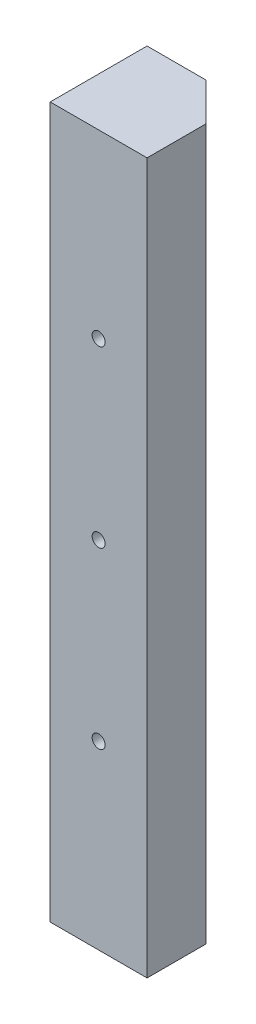
from build123d import *

# Parameters (mm, degrees)
SKETCH1_W                   = 38.1
SKETCH1_H                   = 38.1
BOSS_EXTRUDE1_DEPTH         = 279.4
CHAMFER1_SIZE               = 15
SKETCH15_R                  = 6.35
CUT_EXTRUDE2_DEPTH          = 25
F_1_4_20_TAPPED_HOLE1_D     = 5.1054
F_1_4_20_TAPPED_HOLE1_DEPTH = 20.32
F_1_4_20_TAPPED_HOLE1_TIP   = 1.533816902
F_8_32_TAPPED_HOLE1_REACH   = 285.181
F_8_32_TAPPED_HOLE1_BORE_R  = 1.7272


with BuildPart() as part:
    # Sketch1 → Boss-Extrude1 (new body)
    with BuildSketch(Plane(origin=(0, 0, 0), x_dir=(1, 0, 0), z_dir=(0, 1, 0))):
        with Locations((6.939567467, -5.95)):
            Rectangle(SKETCH1_W, SKETCH1_H)
    extrude(amount=BOSS_EXTRUDE1_DEPTH)

    # Chamfer1
    chamfer1_edges = [part.edges().sort_by_distance(p)[0] for p in [
        (25.989567467, 139.7, -13.1),
    ]]
    chamfer(chamfer1_edges, length=CHAMFER1_SIZE)

    # Sketch15 → Cut-Extrude2 (cut)
    with BuildSketch(Plane(origin=(12.044783734, 0, -12.044783734), x_dir=(-0.7071067811865465, 0, -0.7071067811865487), z_dir=(0.7071067811865487, 0, -0.7071067811865465))):
        with Locations((-9.114300563, 238.76)):
            Circle(SKETCH15_R)
        with Locations((-9.114300563, 177.8)):
            Circle(SKETCH15_R)
        with Locations((-9.114300563, 101.6)):
            Circle(SKETCH15_R)
        with Locations((-9.114300563, 40.64)):
            Circle(SKETCH15_R)
    extrude(amount=-CUT_EXTRUDE2_DEPTH, mode=Mode.SUBTRACT)

    # 1/4-20 Tapped Hole1
    with Locations(Plane.XY.offset(25)):
        with Locations((6.939567467, 208.28), (6.939567467, 139.7), (6.939567467, 71.12)):
            Hole(F_1_4_20_TAPPED_HOLE1_D / 2, depth=F_1_4_20_TAPPED_HOLE1_DEPTH)
            with Locations((0, 0, -(F_1_4_20_TAPPED_HOLE1_DEPTH + F_1_4_20_TAPPED_HOLE1_TIP / 2))):  # 118° drill point
                Cone(0, F_1_4_20_TAPPED_HOLE1_D / 2, F_1_4_20_TAPPED_HOLE1_TIP, mode=Mode.SUBTRACT)

    # #8-32 Tapped Hole1 bore → #8-32 Tapped Hole1 (cut, up to next)
    with BuildSketch(Plane(origin=(0, 0, -13.1), x_dir=(-1, 0, 0), z_dir=(0, 0, -1)), mode=Mode.PRIVATE) as f_8_32_tapped_hole1_sk1:
        with Locations((-7.179567467, 40.64)):
            Circle(F_8_32_TAPPED_HOLE1_BORE_R)
    f_8_32_tapped_hole1_tool1 = extrude(f_8_32_tapped_hole1_sk1.sketch, amount=-F_8_32_TAPPED_HOLE1_REACH, mode=Mode.PRIVATE) & part.part
    # #8-32 Tapped Hole1 bore → #8-32 Tapped Hole1 (cut, up to next)
    with BuildSketch(Plane(origin=(0, 0, -13.1), x_dir=(-1, 0, 0), z_dir=(0, 0, -1)), mode=Mode.PRIVATE) as f_8_32_tapped_hole1_sk2:
        with Locations((-7.179567467, 101.6)):
            Circle(F_8_32_TAPPED_HOLE1_BORE_R)
    f_8_32_tapped_hole1_tool2 = extrude(f_8_32_tapped_hole1_sk2.sketch, amount=-F_8_32_TAPPED_HOLE1_REACH, mode=Mode.PRIVATE) & part.part
    # #8-32 Tapped Hole1 bore → #8-32 Tapped Hole1 (cut, up to next)
    with BuildSketch(Plane(origin=(0, 0, -13.1), x_dir=(-1, 0, 0), z_dir=(0, 0, -1)), mode=Mode.PRIVATE) as f_8_32_tapped_hole1_sk3:
        with Locations((-7.179567467, 177.8)):
            Circle(F_8_32_TAPPED_HOLE1_BORE_R)
    f_8_32_tapped_hole1_tool3 = extrude(f_8_32_tapped_hole1_sk3.sketch, amount=-F_8_32_TAPPED_HOLE1_REACH, mode=Mode.PRIVATE) & part.part
    # #8-32 Tapped Hole1 bore → #8-32 Tapped Hole1 (cut, up to next)
    with BuildSketch(Plane(origin=(0, 0, -13.1), x_dir=(-1, 0, 0), z_dir=(0, 0, -1)), mode=Mode.PRIVATE) as f_8_32_tapped_hole1_sk4:
        with Locations((-7.179567467, 238.76)):
            Circle(F_8_32_TAPPED_HOLE1_BORE_R)
    f_8_32_tapped_hole1_tool4 = extrude(f_8_32_tapped_hole1_sk4.sketch, amount=-F_8_32_TAPPED_HOLE1_REACH, mode=Mode.PRIVATE) & part.part
    add(f_8_32_tapped_hole1_tool1.solids().sort_by_distance((7.179567, 40.64, -13.1))[0], mode=Mode.SUBTRACT)
    add(f_8_32_tapped_hole1_tool2.solids().sort_by_distance((7.179567, 101.6, -13.1))[0], mode=Mode.SUBTRACT)
    add(f_8_32_tapped_hole1_tool3.solids().sort_by_distance((7.179567, 177.8, -13.1))[0], mode=Mode.SUBTRACT)
    add(f_8_32_tapped_hole1_tool4.solids().sort_by_distance((7.179567, 238.76, -13.1))[0], mode=Mode.SUBTRACT)


solid = part.part
